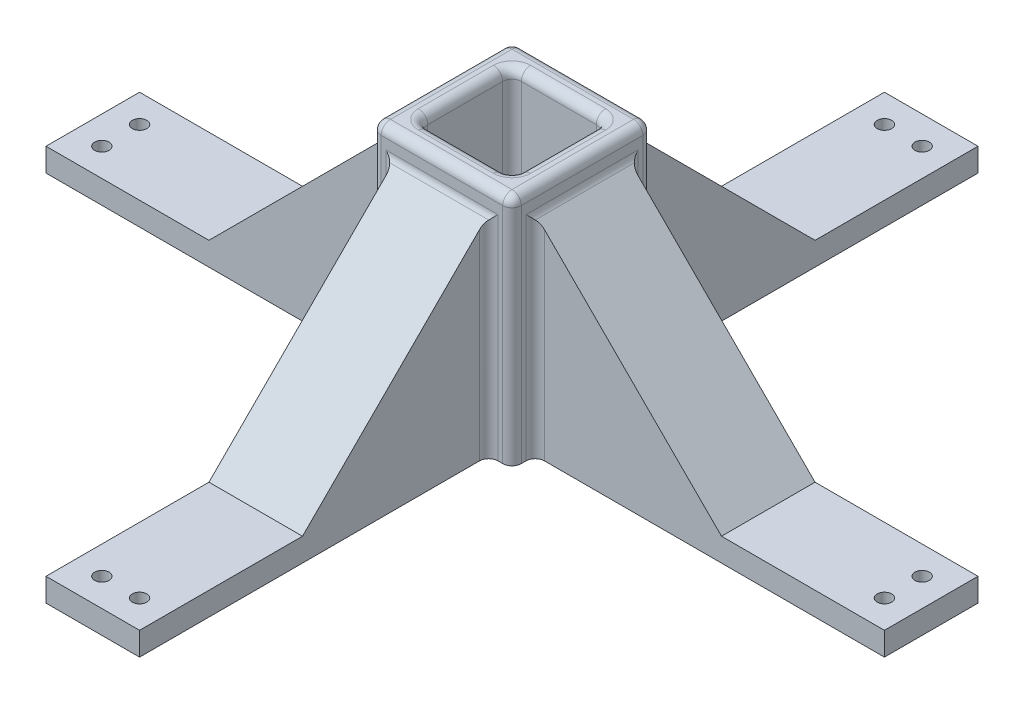
from build123d import *

# Parameters (mm, degrees)
SKETCH1_W             = 75
SKETCH1_H             = 20.1
SKETCH1_R             = 1.55
BOSS_EXTRUDE1_DEPTH   = 5
SKETCH1_W_2           = 20.1
SKETCH1_H_2           = 75
BOSS_EXTRUDE1_2_DEPTH = 5
BOSS_EXTRUDE1_3_DEPTH = 5
BOSS_EXTRUDE1_4_DEPTH = 5
SKETCH1_8_W           = 30.1
SKETCH1_8_H           = 30.1
SKETCH1_8_W_2         = 20.1
SKETCH1_8_H_2         = 20.1
BOSS_EXTRUDE2_DEPTH   = 50
CHAMFER1_SIZE         = 40
FILLET1_R             = 2


with BuildPart() as part:
    # Sketch1 → Boss-Extrude1 (new body)
    with BuildSketch(Plane(origin=(0, 0, 0), x_dir=(1, 0, 0), z_dir=(0, 1, 0))):
        with Locations((42.5, 10.05)):
            Rectangle(SKETCH1_W, SKETCH1_H)
        with Locations((74, 6)):
            Circle(SKETCH1_R, mode=Mode.SUBTRACT)
        with Locations((74, 14.1)):
            Circle(SKETCH1_R, mode=Mode.SUBTRACT)
    extrude(amount=BOSS_EXTRUDE1_DEPTH)



with BuildPart() as body_2:
    # Sketch1 → Boss-Extrude1 2 (new body)
    with BuildSketch(Plane(origin=(0, 0, 0), x_dir=(1, 0, 0), z_dir=(0, 1, 0))):
        with Locations((-10.05, -42.5)):
            Rectangle(SKETCH1_W_2, SKETCH1_H_2)
        with Locations((-14.1, -74)):
            Circle(SKETCH1_R, mode=Mode.SUBTRACT)
        with Locations((-6, -74)):
            Circle(SKETCH1_R, mode=Mode.SUBTRACT)
    extrude(amount=BOSS_EXTRUDE1_2_DEPTH)


with BuildPart() as body_3:
    # Sketch1 → Boss-Extrude1 3 (new body)
    with BuildSketch(Plane(origin=(0, 0, 0), x_dir=(1, 0, 0), z_dir=(0, 1, 0))):
        with Locations((-10.05, 62.6)):
            Rectangle(SKETCH1_W_2, SKETCH1_H_2)
        with Locations((-14.1, 94.1)):
            Circle(SKETCH1_R, mode=Mode.SUBTRACT)
        with Locations((-6, 94.1)):
            Circle(SKETCH1_R, mode=Mode.SUBTRACT)
    extrude(amount=BOSS_EXTRUDE1_3_DEPTH)


with BuildPart() as body_4:
    # Sketch1 → Boss-Extrude1 4 (new body)
    with BuildSketch(Plane(origin=(0, 0, 0), x_dir=(1, 0, 0), z_dir=(0, 1, 0))):
        with Locations((-62.6, 10.05)):
            Rectangle(SKETCH1_W, SKETCH1_H)
        with Locations((-94.1, 6)):
            Circle(SKETCH1_R, mode=Mode.SUBTRACT)
        with Locations((-94.1, 14.1)):
            Circle(SKETCH1_R, mode=Mode.SUBTRACT)
    extrude(amount=BOSS_EXTRUDE1_4_DEPTH)


with BuildPart() as part_1:
    add(part.part)

    add(body_2.part)  # Boss-Extrude2 merges body 2

    add(body_3.part)  # Boss-Extrude2 merges body 3

    add(body_4.part)  # Boss-Extrude2 merges body 4
    # Sketch1_8 → Boss-Extrude2 (add)
    with BuildSketch(Plane(origin=(0, 0, 0), x_dir=(1, 0, 0), z_dir=(0, 1, 0))):
        with Locations((-10.05, 10.05)):
            Rectangle(SKETCH1_8_W, SKETCH1_8_H)
        with Locations((-10.05, 10.05)):
            Rectangle(SKETCH1_8_W_2, SKETCH1_8_H_2, mode=Mode.SUBTRACT)
    extrude(amount=BOSS_EXTRUDE2_DEPTH)

    # Chamfer1
    chamfer1_edges = [part_1.edges().sort_by_distance(p)[0] for p in [
        (-10.05, 5, -25.1),
        (5, 5, -10.05),
        (-10.05, 5, 5),
        (-25.1, 5, -10.05),
    ]]
    chamfer(chamfer1_edges, length=CHAMFER1_SIZE)

    # Fillet1
    fillet1_edges = [part_1.edges().sort_by_distance(p)[0] for p in [
        (-10.05, 50, -20.1),
        (-20.1, 50, -10.05),
        (-10.05, 50, 0),
        (0, 50, -10.05),
        (-25.1, 50, -10.05),
        (-10.05, 50, -25.1),
        (5, 50, -10.05),
        (-10.05, 50, 5),
        (-10.05, 45, 5),
        (5, 45, -10.05),
        (-10.05, 45, -25.1),
        (-25.1, 45, -10.05),
        (-25.1, 22.5, -20.1),
        (-25.1, 25, -25.1),
        (-20.1, 22.5, -25.1),
        (0, 22.5, -25.1),
        (5, 25, -25.1),
        (5, 22.5, -20.1),
        (0, 25, -20.1),
        (0, 22.5, 5),
        (5, 22.5, 0),
        (5, 25, 5),
        (-20.1, 22.5, 5),
        (-25.1, 22.5, 0),
        (-25.1, 25, 5),
        (0, 25, 0),
        (-20.1, 25, 0),
        (-20.1, 25, -20.1),
    ]]
    fillet(fillet1_edges, radius=FILLET1_R)


solid = part_1.part
